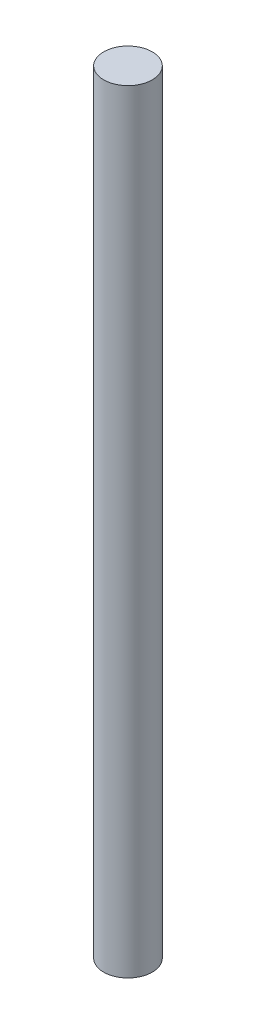
from build123d import *

# Parameters (mm, degrees)
SKETCH1_R           = 27.5
BOSS_EXTRUDE1_DEPTH = 875


with BuildPart() as part:
    # Sketch1 → Boss-Extrude1 (new body)
    with BuildSketch(Plane(origin=(0, 0, 0), x_dir=(1, 0, 0), z_dir=(0, 1, 0))):
        Circle(SKETCH1_R)
    extrude(amount=BOSS_EXTRUDE1_DEPTH)


solid = part.part
